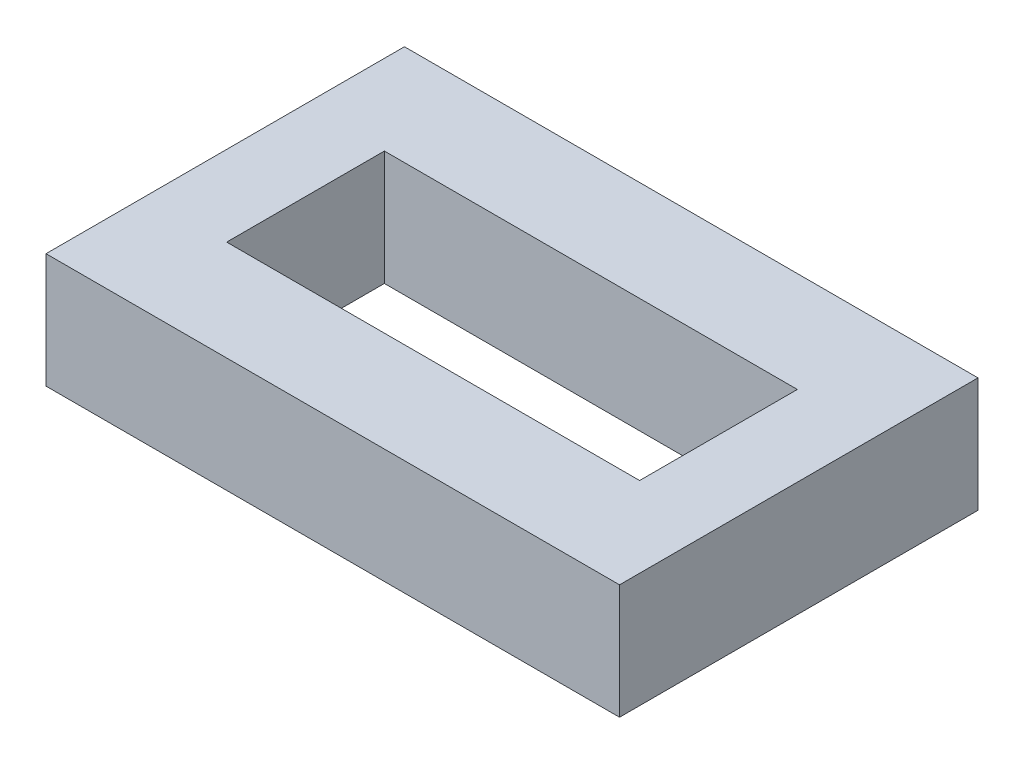
from build123d import *

# Parameters (mm, degrees)
SKETCH1_W           = 50.8
SKETCH1_H           = 31.75
SKETCH1_W_2         = 36.576
SKETCH1_H_2         = 13.97
BOSS_EXTRUDE1_DEPTH = 10.16


with BuildPart() as part:
    # Sketch1 → Boss-Extrude1 (new body)
    with BuildSketch(Plane(origin=(0, 0, 0), x_dir=(1, 0, 0), z_dir=(0, 1, 0))):
        Rectangle(SKETCH1_W, SKETCH1_H)
        Rectangle(SKETCH1_W_2, SKETCH1_H_2, mode=Mode.SUBTRACT)
    extrude(amount=BOSS_EXTRUDE1_DEPTH)


solid = part.part
